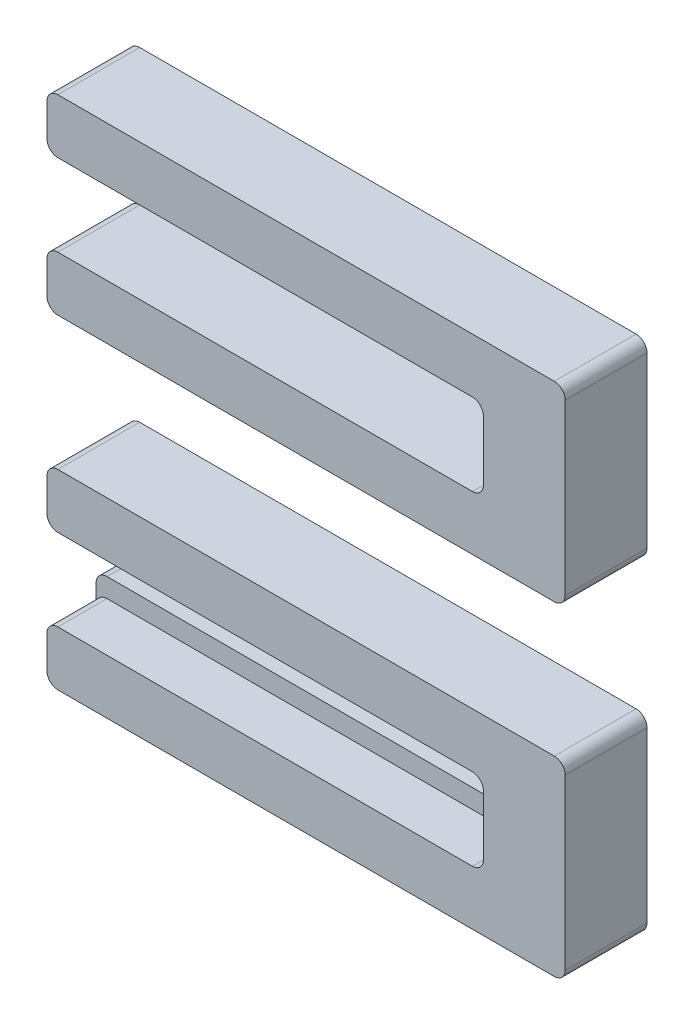
from build123d import *

# Parameters (mm, degrees)
BOSS_EXTRUDE1_DEPTH   = 3
BOSS_EXTRUDE1_2_DEPTH = 3
SKETCH2_4_W           = 16
SKETCH2_4_H           = 0.7
BOSS_EXTRUDE3_DEPTH   = 1.2
FILLET2_R             = 0.4
FILLET3_R             = 0.4


with BuildPart() as part:
    # Sketch2 → Boss-Extrude1 (new body)
    with BuildSketch(Plane.XY):
        Polygon((0, 2), (0, 0), (19, 0), (19, 7), (0, 7), (0, 5), (16, 5), (16, 2), align=None)
    extrude(amount=BOSS_EXTRUDE1_DEPTH)



with BuildPart() as body_2:
    # Sketch2 → Boss-Extrude1 2 (new body)
    with BuildSketch(Plane.XY):
        Polygon((16, -6.899471306), (16, -9.899471306), (0, -9.899471306), (0, -11.899471306), (19, -11.899471306), (19, -4.899471306), (0, -4.899471306), (0, -6.899471306), align=None)
    extrude(amount=BOSS_EXTRUDE1_2_DEPTH)


with BuildPart() as part_1:
    add(part.part)

    add(body_2.part)  # Boss-Extrude3 merges body 2
    # Sketch2_4 → Boss-Extrude3 (add)
    with BuildSketch(Plane.XY):
        with Locations((8, 4.65)):
            Rectangle(SKETCH2_4_W, SKETCH2_4_H)
        with Locations((8, -9.549471306)):
            Rectangle(SKETCH2_4_W, SKETCH2_4_H)
    extrude(amount=BOSS_EXTRUDE3_DEPTH)

    # Fillet2
    fillet2_edges = [part_1.edges().sort_by_distance(p)[0] for p in [
        (0, 5, 2.1),
        (16, 2, 1.5),
        (16, 4.3, 0.6),
        (16, 5, 2.1),
        (19, 7, 1.5),
        (19, 0, 1.5),
        (0, 0, 1.5),
        (0, 2, 1.5),
        (0, 4.3, 0.6),
        (0, 7, 1.5),
    ]]
    fillet(fillet2_edges, radius=FILLET2_R)

    # Fillet3
    fillet3_edges = [part_1.edges().sort_by_distance(p)[0] for p in [
        (19, -11.899471306, 1.5),
        (19, -4.899471306, 1.5),
        (16, -6.899471306, 1.5),
        (16, -9.899471306, 2.1),
        (16, -9.199471306, 0.6),
        (0, -11.899471306, 1.5),
        (0, -9.899471306, 2.1),
        (0, -9.199471306, 0.6),
        (0, -4.899471306, 1.5),
        (0, -6.899471306, 1.5),
    ]]
    fillet(fillet3_edges, radius=FILLET3_R)


solid = part_1.part
